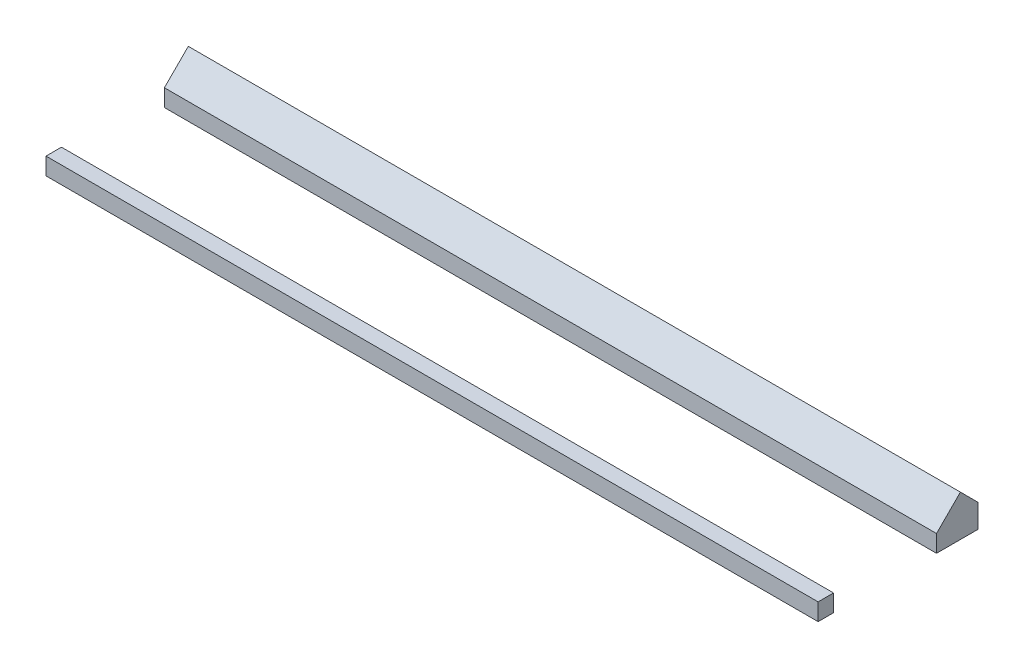
from build123d import *

# Parameters (mm, degrees)
SKETCH2_W             = 18
SKETCH2_H             = 20
BOSS_EXTRUDE1_DEPTH   = 900
BOSS_EXTRUDE1_2_DEPTH = 900


with BuildPart() as part:
    # Sketch2 → Boss-Extrude1 (new body)
    with BuildSketch(Plane(origin=(0, 0, 0), x_dir=(0, 0, -1), z_dir=(1, 0, 0))):
        with Locations((-69, 10)):
            Rectangle(SKETCH2_W, SKETCH2_H)
    extrude(amount=BOSS_EXTRUDE1_DEPTH)


with BuildPart() as body_2:
    # Sketch2 → Boss-Extrude1 2 (new body)
    with BuildSketch(Plane(origin=(0, 0, 0), x_dir=(0, 0, -1), z_dir=(1, 0, 0))):
        Polygon((87.860007179, 47.860007179), (60, 20), (60, 0), (108.366103833, 0), (108.366103833, 27.353910524), align=None)
    extrude(amount=BOSS_EXTRUDE1_2_DEPTH)


solid = Compound([part.part, body_2.part])
